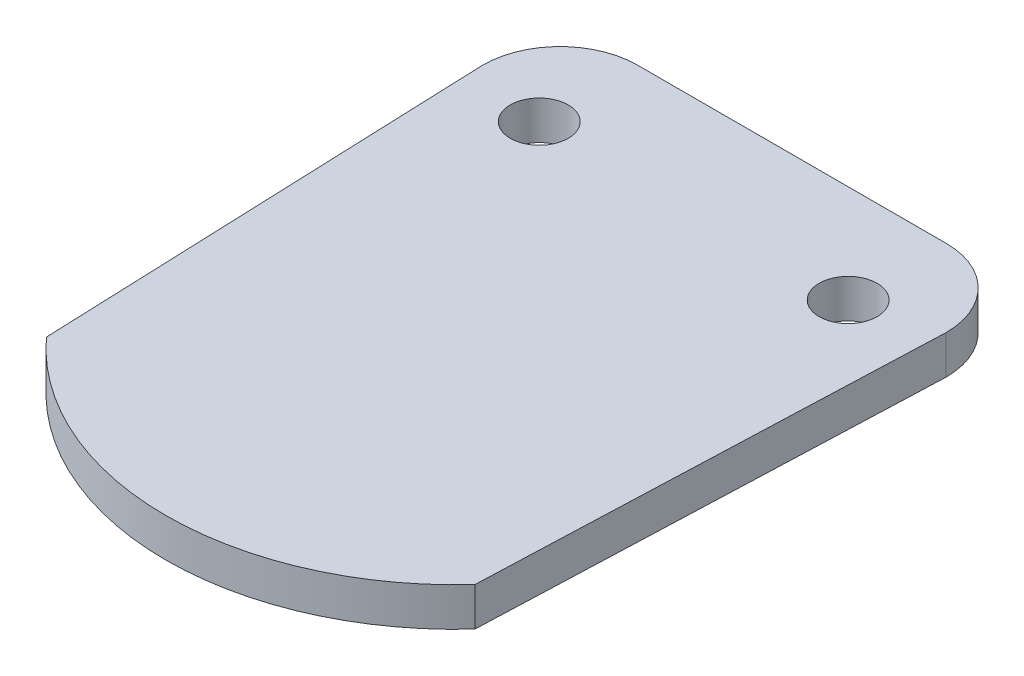
from build123d import *

# Parameters (mm, degrees)
SKETCH1_R           = 1.5
BOSS_EXTRUDE1_DEPTH = 2


with BuildPart() as part:
    # Sketch1 → Boss-Extrude1 (new body)
    with BuildSketch(Plane(origin=(0, 0, 0), x_dir=(1, 0, 0), z_dir=(0, 1, 0))):
        with BuildLine():
            Line((-8, 4), (8, 4))
            ThreePointArc((8, 4), (10.828427125, 2.828427125), (12, 0))
            Line((12, 0), (11.099, -23.51))
            ThreePointArc((11.099, -23.51), (0, -28.41979688), (-11.099, -23.51))
            Line((-11.099, -23.51), (-12, 0))
            ThreePointArc((-12, 0), (-10.828427125, 2.828427125), (-8, 4))
        make_face()
        with Locations((-8, -1.08)):
            Circle(SKETCH1_R, mode=Mode.SUBTRACT)
        with Locations((8, -1.08)):
            Circle(SKETCH1_R, mode=Mode.SUBTRACT)
    extrude(amount=BOSS_EXTRUDE1_DEPTH)


solid = part.part
